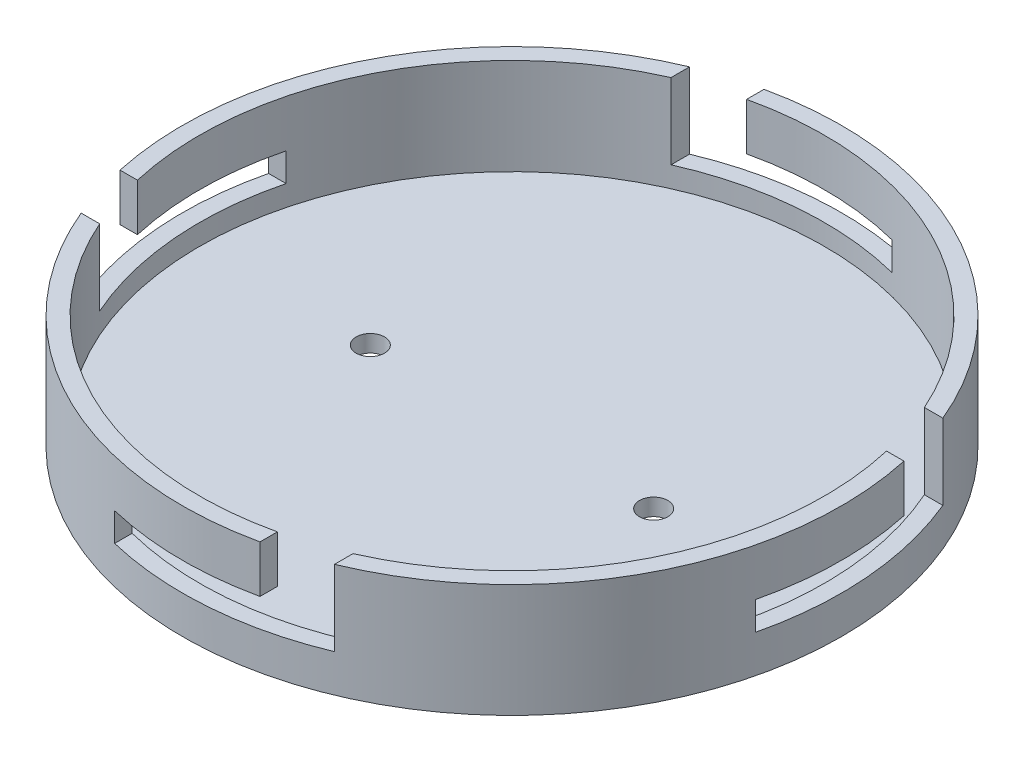
from build123d import *

# Parameters (mm, degrees)
SKIZZE1_R                       = 55.154328933
AUFSATZ_LINEAR_AUSTRAGEN1_DEPTH = 3
SKIZZE1_2_R                     = 58.154328933
SKIZZE1_2_R_2                   = 55.154328933
LINEAR_AUSTRAGEN_D_NN1_DEPTH    = 20
SCHNITT_LINEAR_AUSTRAGEN1_DEPTH = 85.639541275
KREISMUSTER1_COUNT              = 4
SCHNITT_LINEAR_AUSTRAGEN5_REACH = 85.981
SKIZZE4_R                       = 2.5


with BuildPart() as part:
    # Skizze1 → Aufsatz-Linear austragen1 (new body)
    with BuildSketch(Plane(origin=(0, 0, 0), x_dir=(1, 0, 0), z_dir=(0, 1, 0))):
        Circle(SKIZZE1_R)
    extrude(amount=AUFSATZ_LINEAR_AUSTRAGEN1_DEPTH)

    # Skizze1_2 → Linear-Austragen-D_nn1 (add)
    with BuildSketch(Plane(origin=(0, 0, 0), x_dir=(1, 0, 0), z_dir=(0, 1, 0))):
        Circle(SKIZZE1_2_R)
        Circle(SKIZZE1_2_R_2, mode=Mode.SUBTRACT)
    extrude(amount=LINEAR_AUSTRAGEN_D_NN1_DEPTH)

    # Skizze2 → Schnitt-Linear austragen1 (cut, through all)
    with BuildSketch(Plane(origin=(0, 0, 0), x_dir=(0, 0, -1), z_dir=(1, 0, 0))):
        Polygon((-12.349848993, 20), (-22.349848993, 20), (-22.349848993, 6.658478459), (13.585202329, 6.658478459), (13.585202329, 11.658478459), (-12.349848993, 11.658478459), align=None)
    schnitt_linear_austragen1 = extrude(amount=-SCHNITT_LINEAR_AUSTRAGEN1_DEPTH, mode=Mode.SUBTRACT)

    # Kreismuster1: Schnitt-Linear austragen1 ×4 about axis
    kreismuster1_axis = Axis((0, 3, 0), (0, -1, 0))
    for i in range(1, KREISMUSTER1_COUNT):
        add(schnitt_linear_austragen1.rotate(kreismuster1_axis, i * 360 / KREISMUSTER1_COUNT), mode=Mode.SUBTRACT)

    # Skizze4 → Schnitt-Linear austragen5 (cut, up to next)
    with BuildSketch(Plane(origin=(0, 3, 0), x_dir=(1, 0, 0), z_dir=(0, 1, 0)), mode=Mode.PRIVATE) as schnitt_linear_austragen5_sk1:
        with Locations((-25, 0)):
            Circle(SKIZZE4_R)
    schnitt_linear_austragen5_tool1 = extrude(schnitt_linear_austragen5_sk1.sketch, amount=-SCHNITT_LINEAR_AUSTRAGEN5_REACH, mode=Mode.PRIVATE) & part.part
    # Skizze4 → Schnitt-Linear austragen5 (cut, up to next)
    with BuildSketch(Plane(origin=(0, 3, 0), x_dir=(1, 0, 0), z_dir=(0, 1, 0)), mode=Mode.PRIVATE) as schnitt_linear_austragen5_sk2:
        with Locations((25, 0)):
            Circle(SKIZZE4_R)
    schnitt_linear_austragen5_tool2 = extrude(schnitt_linear_austragen5_sk2.sketch, amount=-SCHNITT_LINEAR_AUSTRAGEN5_REACH, mode=Mode.PRIVATE) & part.part
    add(schnitt_linear_austragen5_tool1.solids().sort_by_distance((-25, 3, 0))[0], mode=Mode.SUBTRACT)
    add(schnitt_linear_austragen5_tool2.solids().sort_by_distance((25, 3, 0))[0], mode=Mode.SUBTRACT)


solid = part.part
